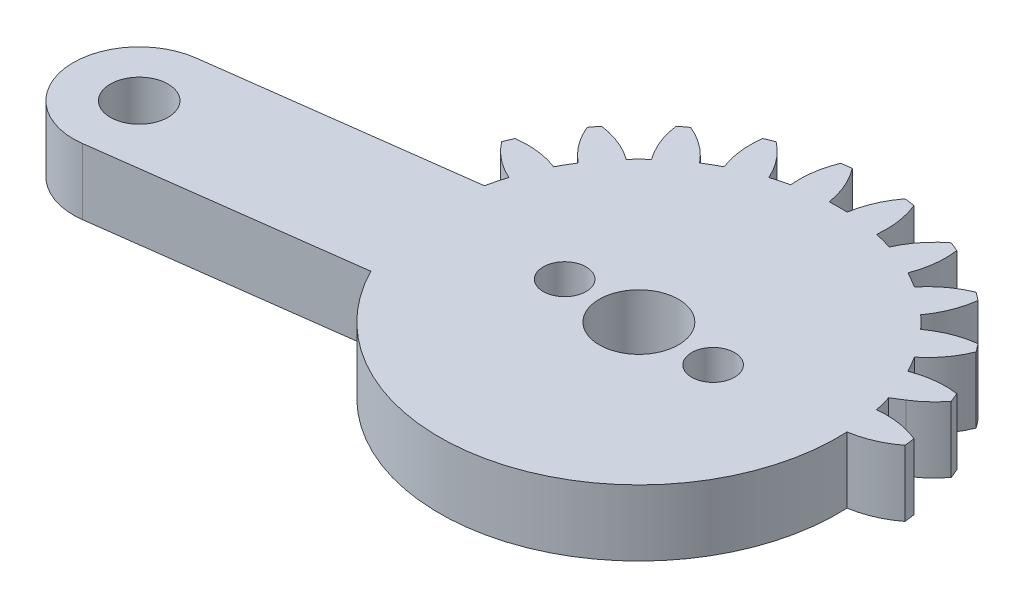
from build123d import *

# Parameters (mm, degrees)
SKETCH1_R           = 1.5
BOSS_EXTRUDE1_DEPTH = 4
SKETCH3_R           = 1.75
BOSS_EXTRUDE2_DEPTH = 4
CUT_EXTRUDE1_DEPTH  = 4
CUT_EXTRUDE2_REACH  = 6
SKETCH5_R           = 1.3
SKETCH5_R_2         = 2.4


with BuildPart() as part:
    # Sketch1 → Boss-Extrude1 (new body)
    with BuildSketch(Plane(origin=(0, 0, 0), x_dir=(1, 0, 0), z_dir=(0, 1, 0))):
        with BuildLine():
            Line((20.643657446, 4), (2.081641936, 4))
            ThreePointArc((2.081641936, 4), (2.861028333, 4.588201733), (3.521749436, 5.30713988))
            ThreePointArc((3.521749436, 5.30713988), (3.405395609, 5.596745198), (3.282888305, 5.883801663))
            ThreePointArc((3.282888305, 5.883801663), (1.93527598, 5.894040025), (0.627094961, 5.57027124))
            ThreePointArc((0.627094961, 5.57027124), (0.366286148, 6.046375), (0.084372603, 6.510293938))
            ThreePointArc((0.084372603, 6.510293938), (1.018855105, 7.48132754), (1.683794586, 8.65351323))
            ThreePointArc((1.683794586, 8.65351323), (1.496450048, 8.903135899), (1.303821399, 9.148703928))
            ThreePointArc((1.303821399, 9.148703928), (-0.000522033, 8.809805691), (-1.180330337, 8.158486898))
            ThreePointArc((-1.180330337, 8.158486898), (-1.555477026, 8.550865528), (-1.947855656, 8.926012217))
            ThreePointArc((-1.947855656, 8.926012217), (-1.296536862, 10.105820521), (-0.957638625, 11.410163953))
            ThreePointArc((-0.957638625, 11.410163953), (-1.203206655, 11.602792602), (-1.452829324, 11.79013714))
            ThreePointArc((-1.452829324, 11.79013714), (-2.625015014, 11.125197659), (-3.596048616, 10.190715157))
            ThreePointArc((-3.596048616, 10.190715157), (-4.059967554, 10.472628702), (-4.536071314, 10.733437515))
            ThreePointArc((-4.536071314, 10.733437515), (-4.212302529, 12.041618533), (-4.222540891, 13.389230859))
            ThreePointArc((-4.222540891, 13.389230859), (-4.509597355, 13.511738163), (-4.799202674, 13.62809199))
            ThreePointArc((-4.799202674, 13.62809199), (-5.759348103, 12.682425791), (-6.455432668, 11.528463019))
            ThreePointArc((-6.455432668, 11.528463019), (-6.976508546, 11.680699536), (-7.503891752, 11.809396783))
            ThreePointArc((-7.503891752, 11.809396783), (-7.529737283, 13.156800143), (-7.888414517, 14.455843809))
            ThreePointArc((-7.888414517, 14.455843809), (-8.197396993, 14.499881098), (-8.507248835, 14.537314892))
            ThreePointArc((-8.507248835, 14.537314892), (-9.18992168, 13.375367565), (-9.563620196, 12.080565177))
            ThreePointArc((-9.563620196, 12.080565177), (-10.106342554, 12.09275), (-10.649064912, 12.080565177))
            ThreePointArc((-10.649064912, 12.080565177), (-11.022763428, 13.375367565), (-11.705436272, 14.537314892))
            ThreePointArc((-11.705436272, 14.537314892), (-12.015288115, 14.499881098), (-12.324270591, 14.455843809))
            ThreePointArc((-12.324270591, 14.455843809), (-12.682947825, 13.156800143), (-12.708793355, 11.809396783))
            ThreePointArc((-12.708793355, 11.809396783), (-13.236176561, 11.680699536), (-13.757252439, 11.528463019))
            ThreePointArc((-13.757252439, 11.528463019), (-14.453337005, 12.682425791), (-15.413482434, 13.62809199))
            ThreePointArc((-15.413482434, 13.62809199), (-15.703087752, 13.511738163), (-15.990144217, 13.389230859))
            ThreePointArc((-15.990144217, 13.389230859), (-16.000382579, 12.041618533), (-15.676613793, 10.733437515))
            ThreePointArc((-15.676613793, 10.733437515), (-16.152717554, 10.472628702), (-16.616636492, 10.190715157))
            ThreePointArc((-16.616636492, 10.190715157), (-17.587670094, 11.125197659), (-18.759855783, 11.79013714))
            ThreePointArc((-18.759855783, 11.79013714), (-19.009478453, 11.602792602), (-19.255046482, 11.410163953))
            ThreePointArc((-19.255046482, 11.410163953), (-18.916148245, 10.105820521), (-18.264829452, 8.926012217))
            ThreePointArc((-18.264829452, 8.926012217), (-18.657208082, 8.550865528), (-19.032354771, 8.158486898))
            ThreePointArc((-19.032354771, 8.158486898), (-20.212163074, 8.809805691), (-21.516506507, 9.148703928))
            ThreePointArc((-21.516506507, 9.148703928), (-21.709135156, 8.903135899), (-21.896479694, 8.65351323))
            ThreePointArc((-21.896479694, 8.65351323), (-21.231540213, 7.48132754), (-20.297057711, 6.510293938))
            ThreePointArc((-20.297057711, 6.510293938), (-20.578971255, 6.046375), (-20.839780068, 5.57027124))
            ThreePointArc((-20.839780068, 5.57027124), (-22.147961087, 5.894040025), (-23.495573413, 5.883801663))
            ThreePointArc((-23.495573413, 5.883801663), (-23.618080717, 5.596745198), (-23.734434544, 5.30713988))
            ThreePointArc((-23.734434544, 5.30713988), (-22.788768345, 4.346994451), (-21.634805572, 3.650909885))
            ThreePointArc((-21.634805572, 3.650909885), (-21.78704209, 3.129834008), (-21.915739337, 2.602450802))
            ThreePointArc((-21.915739337, 2.602450802), (-23.263142697, 2.576605271), (-24.562186363, 2.217928037))
            ThreePointArc((-24.562186363, 2.217928037), (-24.606223651, 1.908945561), (-24.643657446, 1.599093719))
            ThreePointArc((-24.643657446, 1.599093719), (-23.481710119, 0.916420874), (-22.186907731, 0.542722358))
            ThreePointArc((-22.186907731, 0.542722358), (-22.199092554, 0), (-22.186907731, -0.542722358))
            ThreePointArc((-22.186907731, -0.542722358), (-23.481710119, -0.916420874), (-24.643657446, -1.599093719))
            ThreePointArc((-24.643657446, -1.599093719), (-24.606223651, -1.908945561), (-24.562186363, -2.217928037))
            ThreePointArc((-24.562186363, -2.217928037), (-23.263142697, -2.576605271), (-21.915739337, -2.602450802))
            ThreePointArc((-21.915739337, -2.602450802), (-21.78704209, -3.129834008), (-21.634805572, -3.650909885))
            ThreePointArc((-21.634805572, -3.650909885), (-22.788768345, -4.346994451), (-23.734434544, -5.30713988))
            ThreePointArc((-23.734434544, -5.30713988), (-23.618080717, -5.596745198), (-23.495573413, -5.883801663))
            ThreePointArc((-23.495573413, -5.883801663), (-22.147961087, -5.894040025), (-20.839780068, -5.57027124))
            ThreePointArc((-20.839780068, -5.57027124), (-20.578971255, -6.046375), (-20.297057711, -6.510293938))
            ThreePointArc((-20.297057711, -6.510293938), (-21.231540213, -7.48132754), (-21.896479694, -8.65351323))
            ThreePointArc((-21.896479694, -8.65351323), (-21.709135156, -8.903135899), (-21.516506507, -9.148703928))
            ThreePointArc((-21.516506507, -9.148703928), (-20.212163074, -8.809805691), (-19.032354771, -8.158486898))
            ThreePointArc((-19.032354771, -8.158486898), (-18.657208082, -8.550865528), (-18.264829452, -8.926012217))
            ThreePointArc((-18.264829452, -8.926012217), (-18.916148245, -10.105820521), (-19.255046482, -11.410163953))
            ThreePointArc((-19.255046482, -11.410163953), (-19.009478453, -11.602792602), (-18.759855783, -11.79013714))
            ThreePointArc((-18.759855783, -11.79013714), (-17.587670094, -11.125197659), (-16.616636492, -10.190715157))
            ThreePointArc((-16.616636492, -10.190715157), (-16.152717554, -10.472628702), (-15.676613793, -10.733437515))
            ThreePointArc((-15.676613793, -10.733437515), (-16.000382579, -12.041618533), (-15.990144217, -13.389230859))
            ThreePointArc((-15.990144217, -13.389230859), (-15.703087752, -13.511738163), (-15.413482434, -13.62809199))
            ThreePointArc((-15.413482434, -13.62809199), (-14.453337005, -12.682425791), (-13.757252439, -11.528463019))
            ThreePointArc((-13.757252439, -11.528463019), (-13.236176561, -11.680699536), (-12.708793355, -11.809396783))
            ThreePointArc((-12.708793355, -11.809396783), (-12.682947825, -13.156800143), (-12.324270591, -14.455843809))
            ThreePointArc((-12.324270591, -14.455843809), (-12.015288115, -14.499881098), (-11.705436272, -14.537314892))
            ThreePointArc((-11.705436272, -14.537314892), (-11.022763428, -13.375367565), (-10.649064912, -12.080565177))
            ThreePointArc((-10.649064912, -12.080565177), (-10.106342554, -12.09275), (-9.563620196, -12.080565177))
            ThreePointArc((-9.563620196, -12.080565177), (-9.18992168, -13.375367565), (-8.507248835, -14.537314892))
            ThreePointArc((-8.507248835, -14.537314892), (-8.197396993, -14.499881098), (-7.888414517, -14.455843809))
            ThreePointArc((-7.888414517, -14.455843809), (-7.529737283, -13.156800143), (-7.503891752, -11.809396783))
            ThreePointArc((-7.503891752, -11.809396783), (-6.976508546, -11.680699536), (-6.455432668, -11.528463019))
            ThreePointArc((-6.455432668, -11.528463019), (-5.759348103, -12.682425791), (-4.799202674, -13.62809199))
            ThreePointArc((-4.799202674, -13.62809199), (-4.509597355, -13.511738163), (-4.222540891, -13.389230859))
            ThreePointArc((-4.222540891, -13.389230859), (-4.212302529, -12.041618533), (-4.536071314, -10.733437515))
            ThreePointArc((-4.536071314, -10.733437515), (-4.059967554, -10.472628702), (-3.596048616, -10.190715157))
            ThreePointArc((-3.596048616, -10.190715157), (-2.625015014, -11.125197659), (-1.452829324, -11.79013714))
            ThreePointArc((-1.452829324, -11.79013714), (-1.203206655, -11.602792602), (-0.957638625, -11.410163953))
            ThreePointArc((-0.957638625, -11.410163953), (-1.296536862, -10.105820521), (-1.947855656, -8.926012217))
            ThreePointArc((-1.947855656, -8.926012217), (-1.555477026, -8.550865528), (-1.180330337, -8.158486898))
            ThreePointArc((-1.180330337, -8.158486898), (-0.000522033, -8.809805691), (1.303821399, -9.148703928))
            ThreePointArc((1.303821399, -9.148703928), (1.496450048, -8.903135899), (1.683794586, -8.65351323))
            ThreePointArc((1.683794586, -8.65351323), (1.018855105, -7.48132754), (0.084372603, -6.510293938))
            ThreePointArc((0.084372603, -6.510293938), (0.366286148, -6.046375), (0.627094961, -5.57027124))
            ThreePointArc((0.627094961, -5.57027124), (1.93527598, -5.894040025), (3.282888305, -5.883801663))
            ThreePointArc((3.282888305, -5.883801663), (3.405395609, -5.596745198), (3.521749436, -5.30713988))
            ThreePointArc((3.521749436, -5.30713988), (2.861028333, -4.588201733), (2.081641936, -4))
            Line((2.081641936, -4), (20.643657446, -4))
            ThreePointArc((20.643657446, -4), (24.643657446, 0), (20.643657446, 4))
        make_face()
        with Locations((-10.106342554, 0)):
            Circle(SKETCH1_R, mode=Mode.SUBTRACT)
        with Locations((20.643657446, 0)):
            Circle(SKETCH1_R, mode=Mode.SUBTRACT)
    extrude(amount=BOSS_EXTRUDE1_DEPTH)

    # Sketch3 → Boss-Extrude2 (add)
    with BuildSketch(Plane(origin=(0, 4, 0), x_dir=(1, 0, 0), z_dir=(0, 1, 0))):
        with BuildLine():
            ThreePointArc((-9.584237785, -3.965779445), (-14.072121999, -0.522104769), (-10.628447323, 3.965779445))
            Line((-10.628447323, 3.965779445), (-37.39745858, 0.441572256))
            ThreePointArc((-37.39745858, 0.441572256), (-40.841133256, -4.046311959), (-36.353249042, -7.489986635))
            Line((-36.353249042, -7.489986635), (-9.584237785, -3.965779445))
        make_face()
        with Locations((-36.875353811, -3.52420719)):
            Circle(SKETCH3_R, mode=Mode.SUBTRACT)
    extrude(amount=-BOSS_EXTRUDE2_DEPTH)

    # Sketch4 → Cut-Extrude1 (cut)
    with BuildSketch(Plane(origin=(0, 4, 0), x_dir=(1, 0, 0), z_dir=(0, 1, 0))):
        with BuildLine():
            ThreePointArc((20.643657446, -4), (24.643657446, 0), (20.643657446, 4))
            Line((20.643657446, 4), (2.081641936, 4))
            Line((2.081641936, 4), (1.43808022, 3.600125745))
            ThreePointArc((1.43808022, 3.600125745), (1.581217534, 3.104116905), (1.70305423, 2.602450802))
            ThreePointArc((1.70305423, 2.602450802), (3.050457589, 2.576605271), (4.349501255, 2.217928037))
            ThreePointArc((4.349501255, 2.217928037), (4.393538544, 1.908945561), (4.430972339, 1.599093719))
            ThreePointArc((4.430972339, 1.599093719), (3.269025011, 0.916420874), (1.974222624, 0.542722358))
            ThreePointArc((1.974222624, 0.542722358), (1.70305423, -2.602450802), (0.627094961, -5.57027124))
            ThreePointArc((0.627094961, -5.57027124), (1.93527598, -5.894040025), (3.282888305, -5.883801663))
            ThreePointArc((3.282888305, -5.883801663), (3.405395609, -5.596745198), (3.521749436, -5.30713988))
            ThreePointArc((3.521749436, -5.30713988), (2.861028333, -4.588201733), (2.081641936, -4))
            Line((2.081641936, -4), (20.643657446, -4))
        make_face()
        with BuildLine():
            ThreePointArc((1.683794586, -8.65351323), (1.018855105, -7.48132754), (0.084372603, -6.510293938))
            ThreePointArc((0.084372603, -6.510293938), (-0.512518948, -7.361599771), (-1.180330337, -8.158486898))
            ThreePointArc((-1.180330337, -8.158486898), (-0.000522033, -8.809805691), (1.303821399, -9.148703928))
            ThreePointArc((1.303821399, -9.148703928), (1.496450048, -8.903135899), (1.683794586, -8.65351323))
        make_face()
        with BuildLine():
            ThreePointArc((-0.957638625, -11.410163953), (-1.296536862, -10.105820521), (-1.947855656, -8.926012217))
            ThreePointArc((-1.947855656, -8.926012217), (-2.744742783, -9.593823606), (-3.596048616, -10.190715157))
            ThreePointArc((-3.596048616, -10.190715157), (-2.625015014, -11.125197659), (-1.452829324, -11.79013714))
            ThreePointArc((-1.452829324, -11.79013714), (-1.203206655, -11.602792602), (-0.957638625, -11.410163953))
        make_face()
        with BuildLine():
            ThreePointArc((-4.222540891, -13.389230859), (-4.212302529, -12.041618533), (-4.536071314, -10.733437515))
            ThreePointArc((-4.536071314, -10.733437515), (-5.478647477, -11.172244217), (-6.455432668, -11.528463019))
            ThreePointArc((-6.455432668, -11.528463019), (-5.759348103, -12.682425791), (-4.799202674, -13.62809199))
            ThreePointArc((-4.799202674, -13.62809199), (-4.509597355, -13.511738163), (-4.222540891, -13.389230859))
        make_face()
        with BuildLine():
            ThreePointArc((-7.888414517, -14.455843809), (-7.529737283, -13.156800143), (-7.503891752, -11.809396783))
            ThreePointArc((-7.503891752, -11.809396783), (-8.527921943, -11.989294847), (-9.563620196, -12.080565177))
            ThreePointArc((-9.563620196, -12.080565177), (-9.18992168, -13.375367565), (-8.507248835, -14.537314892))
            ThreePointArc((-8.507248835, -14.537314892), (-8.197396993, -14.499881098), (-7.888414517, -14.455843809))
        make_face()
        with BuildLine():
            ThreePointArc((-11.705436272, -14.537314892), (-11.022763428, -13.375367565), (-10.649064912, -12.080565177))
            ThreePointArc((-10.649064912, -12.080565177), (-11.684763165, -11.989294847), (-12.708793355, -11.809396783))
            ThreePointArc((-12.708793355, -11.809396783), (-12.682947825, -13.156800143), (-12.324270591, -14.455843809))
            ThreePointArc((-12.324270591, -14.455843809), (-12.015288115, -14.499881098), (-11.705436272, -14.537314892))
        make_face()
        with BuildLine():
            ThreePointArc((-15.413482434, -13.62809199), (-14.453337005, -12.682425791), (-13.757252439, -11.528463019))
            ThreePointArc((-13.757252439, -11.528463019), (-14.734037631, -11.172244217), (-15.676613793, -10.733437515))
            ThreePointArc((-15.676613793, -10.733437515), (-16.000382579, -12.041618533), (-15.990144217, -13.389230859))
            ThreePointArc((-15.990144217, -13.389230859), (-15.703087752, -13.511738163), (-15.413482434, -13.62809199))
        make_face()
        with BuildLine():
            ThreePointArc((-18.759855783, -11.79013714), (-17.587670094, -11.125197659), (-16.616636492, -10.190715157))
            ThreePointArc((-16.616636492, -10.190715157), (-17.467942324, -9.593823606), (-18.264829452, -8.926012217))
            ThreePointArc((-18.264829452, -8.926012217), (-18.916148245, -10.105820521), (-19.255046482, -11.410163953))
            ThreePointArc((-19.255046482, -11.410163953), (-19.009478453, -11.602792602), (-18.759855783, -11.79013714))
        make_face()
        with BuildLine():
            ThreePointArc((-21.516506507, -9.148703928), (-20.212163074, -8.809805691), (-19.032354771, -8.158486898))
            ThreePointArc((-19.032354771, -8.158486898), (-19.70016616, -7.361599771), (-20.297057711, -6.510293938))
            ThreePointArc((-20.297057711, -6.510293938), (-21.231540213, -7.48132754), (-21.896479694, -8.65351323))
            ThreePointArc((-21.896479694, -8.65351323), (-21.709135156, -8.903135899), (-21.516506507, -9.148703928))
        make_face()
        with BuildLine():
            ThreePointArc((-21.942853375, 2.47620963), (-21.92946485, 2.539366405), (-21.915739337, 2.602450802))
            ThreePointArc((-21.915739337, 2.602450802), (-23.263142697, 2.576605271), (-24.562186363, 2.217928037))
            ThreePointArc((-24.562186363, 2.217928037), (-24.56889027, 2.173784387), (-24.575459377, 2.129620475))
            Line((-24.575459377, 2.129620475), (-21.942853375, 2.47620963))
        make_face()
        with BuildLine():
            ThreePointArc((-23.495573413, -5.883801663), (-22.147961087, -5.894040025), (-20.839780068, -5.57027124))
            ThreePointArc((-20.839780068, -5.57027124), (-20.869365339, -5.512888815), (-20.898643838, -5.455349261))
            Line((-20.898643838, -5.455349261), (-23.531249839, -5.801938416))
            ThreePointArc((-23.531249839, -5.801938416), (-23.513474108, -5.842897269), (-23.495573413, -5.883801663))
        make_face()
    extrude(amount=-CUT_EXTRUDE1_DEPTH, mode=Mode.SUBTRACT)

    # Sketch5 → Cut-Extrude2 (cut, up to next)
    with BuildSketch(Plane(origin=(0, 4, 0), x_dir=(1, 0, 0), z_dir=(0, 1, 0)), mode=Mode.PRIVATE) as cut_extrude2_sk1:
        with Locations((-14.606342554, 0)):
            Circle(SKETCH5_R)
    cut_extrude2_tool1 = extrude(cut_extrude2_sk1.sketch, amount=-CUT_EXTRUDE2_REACH, mode=Mode.PRIVATE) & part.part
    add(cut_extrude2_tool1.solids().sort_by_distance((-14.606343, 4, 0))[0], mode=Mode.SUBTRACT)
    # Sketch5 → Cut-Extrude2 (cut, up to next)
    with BuildSketch(Plane(origin=(0, 4, 0), x_dir=(1, 0, 0), z_dir=(0, 1, 0)), mode=Mode.PRIVATE) as cut_extrude2_sk2:
        with Locations((-5.606342554, 0)):
            Circle(SKETCH5_R)
    cut_extrude2_tool2 = extrude(cut_extrude2_sk2.sketch, amount=-CUT_EXTRUDE2_REACH, mode=Mode.PRIVATE) & part.part
    add(cut_extrude2_tool2.solids().sort_by_distance((-5.606343, 4, 0))[0], mode=Mode.SUBTRACT)
    # Sketch5 → Cut-Extrude2 (cut, up to next)
    with BuildSketch(Plane(origin=(0, 4, 0), x_dir=(1, 0, 0), z_dir=(0, 1, 0)), mode=Mode.PRIVATE) as cut_extrude2_sk3:
        with Locations((-10.106342554, 0)):
            Circle(SKETCH5_R_2)
    cut_extrude2_tool3 = extrude(cut_extrude2_sk3.sketch, amount=-CUT_EXTRUDE2_REACH, mode=Mode.PRIVATE) & part.part
    add(cut_extrude2_tool3.solids().sort_by_distance((-10.106343, 4, 0))[0], mode=Mode.SUBTRACT)


solid = part.part
